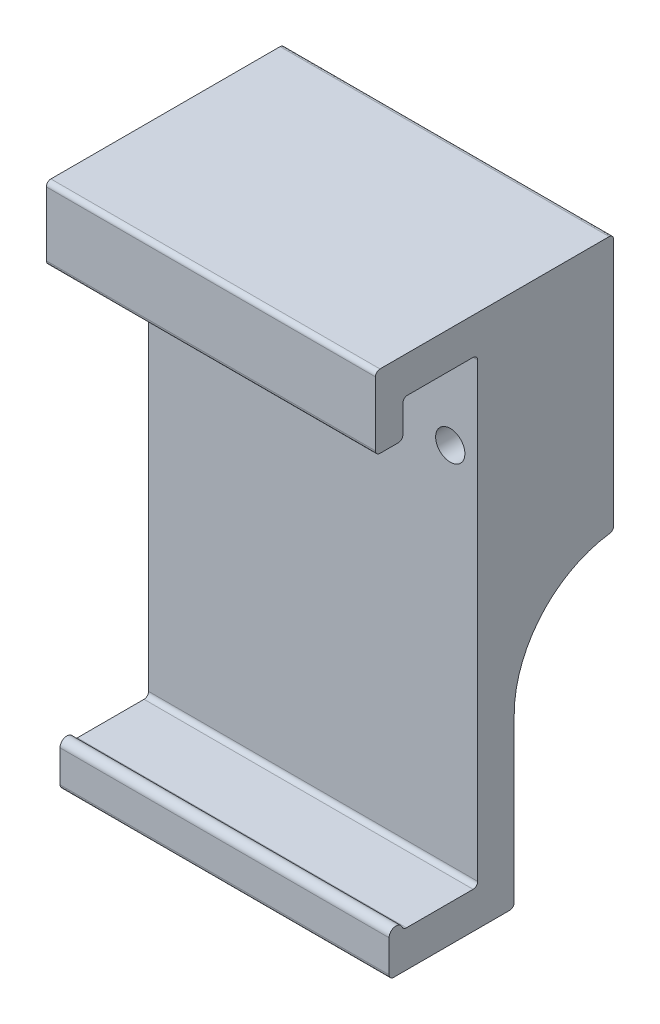
from build123d import *

# Parameters (mm, degrees)
BOSS_EXTRUDE1_DEPTH = 14.2875
FILLET1_R           = 0.396875
BOSS_EXTRUDE2_DEPTH = 14.2875
FILLET2_R           = 0.396875
SKETCH5_R           = 1.27
CUT_EXTRUDE1_DEPTH  = 12.7
FILLET3_R           = 9.525


with BuildPart() as part:
    # Sketch2 → Boss-Extrude1 (new, symmetric)
    with BuildSketch(Plane(origin=(0, 0, 0), x_dir=(0, 0, -1), z_dir=(1, 0, 0))):
        with BuildLine():
            Line((-3.25, 16.825), (-5.63125, 16.825))
            Line((-5.63125, 16.825), (-5.63125, 23.175))
            Line((-5.63125, 23.175), (6.425, 23.175))
            Line((6.425, 23.175), (6.425, -23.175))
            Line((6.425, -23.175), (-4.440625, -23.175))
            Line((-4.440625, -23.175), (-4.440625, -20))
            ThreePointArc((-4.440625, -20), (-3.8453125, -19.4046875), (-3.25, -20))
            Line((-3.25, -20), (3.25, -20))
            Line((3.25, -20), (3.25, 20))
            Line((3.25, 20), (-3.25, 20))
            Line((-3.25, 20), (-3.25, 16.825))
        make_face()
    extrude(amount=BOSS_EXTRUDE1_DEPTH, both=True)

    # Fillet1
    fillet1_edges = [part.edges().sort_by_distance(p)[0] for p in [
        (0, 16.825, 3.25),
        (0, 16.825, 5.63125),
        (0, 23.175, 5.63125),
        (0, -23.175, 4.440625),
        (0, 20, -3.25),
        (0, 20, 3.25),
        (0, -20, -3.25),
        (0, -20, 3.25),
    ]]
    fillet(fillet1_edges, radius=FILLET1_R)

    # Sketch3 → Boss-Extrude2 (add, symmetric)
    with BuildSketch(Plane(origin=(0, 0, 0), x_dir=(0, 0, -1), z_dir=(1, 0, 0))):
        Polygon((6.425, 23.175), (15.061, 23.175), (15.061, 20.635), (15.061, 3.363), (15.061, 0.823), (6.425, 0.823), align=None)
    extrude(amount=BOSS_EXTRUDE2_DEPTH, both=True)

    # Sketch4 → Cut-Revolve3 (revolve, cut)
    with BuildSketch(Plane(origin=(0, 0, 0), x_dir=(0, 0, -1), z_dir=(1, 0, 0))):
        with BuildLine():
            Line((15.061, 3.363), (15.061, 20.635))
            ThreePointArc((15.061, 20.635), (6.425, 11.999), (15.061, 3.363))
        make_face()
    revolve(axis=Axis((0, 3.363, -15.061), (0, 1, 0)), mode=Mode.SUBTRACT)

    # Fillet2
    fillet2_edges = [part.edges().sort_by_distance(p)[0] for p in [
        (8.636, 11.999, -15.061),
        (0, 23.175, -15.061),
        (0, 0.823, -15.061),
        (0, -23.175, -6.425),
    ]]
    fillet(fillet2_edges, radius=FILLET2_R)

    # Sketch5 → Cut-Extrude1 (cut)
    with BuildSketch(Plane(origin=(0, 0, -15.061), x_dir=(-1, 0, 0), z_dir=(0, 0, -1))):
        with Locations((-11.90625, 11.999)):
            Circle(SKETCH5_R)
        with Locations((11.90625, 11.999)):
            Circle(SKETCH5_R)
    extrude(amount=-CUT_EXTRUDE1_DEPTH, mode=Mode.SUBTRACT)

    # Fillet3
    fillet3_edges = [part.edges().sort_by_distance(p)[0] for p in [
        (0, 0.823, -6.425),
    ]]
    fillet(fillet3_edges, radius=FILLET3_R)


solid = part.part
